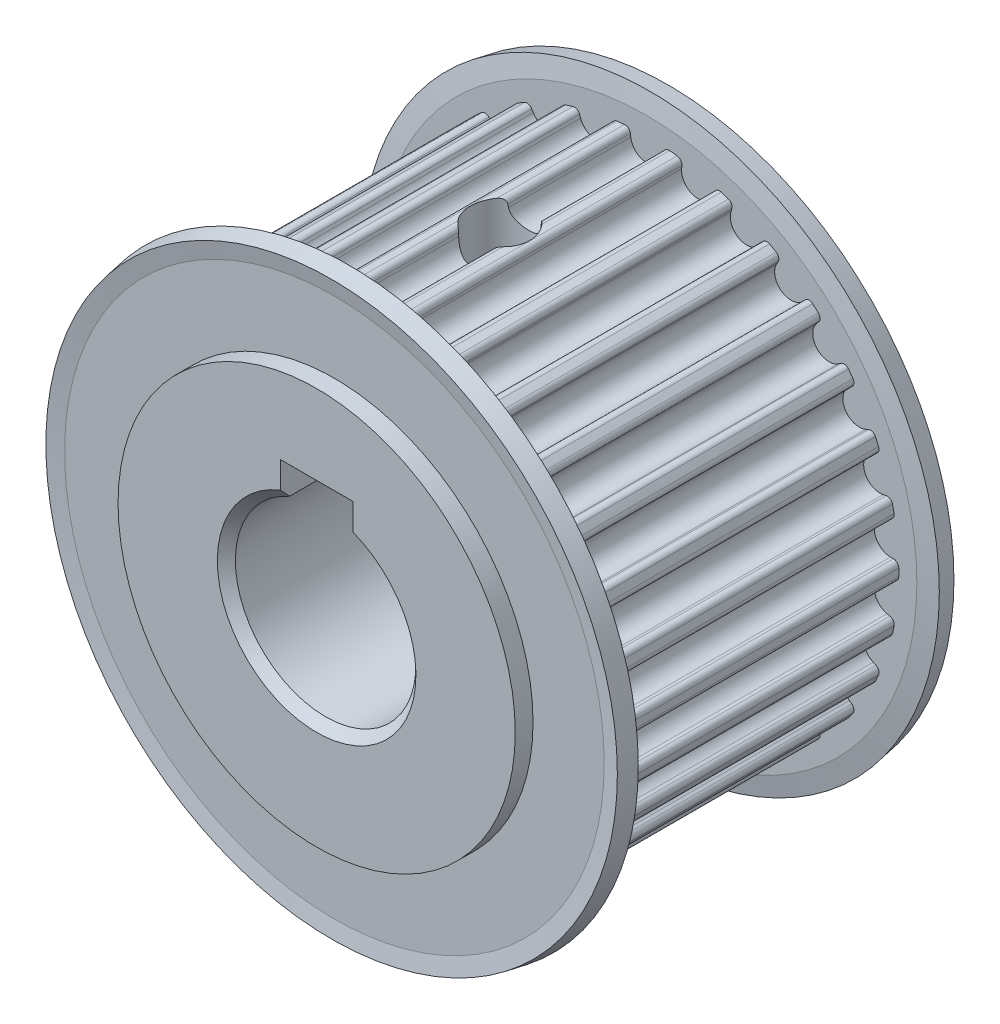
from build123d import *

# Parameters (mm, degrees)
TOOTH_EXTRUDE_START      = -8.15
TOOTH_EXTRUDE_DEPTH      = 16.3
TOOTH_PATTERN_COUNT      = 30
SKETCH_1_R               = 5
SKETCH_1_W               = 4
SKETCH_1_H               = 3.17973871
CUT_EXTRUDE_1_DEPTH      = 40
CHAMFER_1_SIZE           = 0.5
HOLE_WIZARD_M3_1_D       = 2.5
HOLE_WIZARD_M3_1_DEPTH   = 8.5
HOLE_WIZARD_M3_1_TIP     = 0.751075774
SKETCH_4_W               = 1.65
SKETCH_4_H               = 16
PATTERN_CIRCULAR_1_COUNT = 2
PATTERN_CIRCULAR_1_ANGLE = 90


with BuildPart() as part:
    # GearBelt-BaseSketch → HTD 5mm (revolve)
    with BuildSketch(Plane(origin=(0, 0, 0), x_dir=(0, 0, -1), z_dir=(1, 0, 0))):
        Polygon((-10.15, 0), (10.15, 0), (10.15, 11), (9.165426612, 11), (9.165426612, 14.942945123), (9.321195048, 15.826351822), (8.336387295, 16), (8.15, 14.942945123), (8.15, 13.942945123), (-8.15, 13.942945123), (-8.15, 14.942945123), (-8.336387295, 16), (-9.321195048, 15.826351822), (-9.165426612, 14.942945123), (-9.165426612, 11), (-10.15, 11), align=None)
    revolve(axis=Axis((0, 0, 10.8585), (0, 0, -1)))

    # Tooth-Sketch → Tooth-Extrude (cut)
    with BuildSketch(Plane.XY.offset(TOOTH_EXTRUDE_START)):
        with BuildLine():
            Line((-0.903216998, 13.46204402), (-0.923196237, 13.624761865))
            ThreePointArc((-0.923196237, 13.624761865), (-1.032437726, 13.821566271), (-1.247808246, 13.886997273))
            ThreePointArc((-1.247808246, 13.886997273), (0, 13.942945123), (1.247808246, 13.886997273))
            ThreePointArc((1.247808246, 13.886997273), (1.032437726, 13.821566271), (0.923196237, 13.624761865))
            Line((0.923196237, 13.624761865), (0.903216998, 13.46204402))
            ThreePointArc((0.903216998, 13.46204402), (0, 12.662945123), (-0.903216998, 13.46204402))
        make_face()
    tooth_extrude = extrude(amount=TOOTH_EXTRUDE_DEPTH, mode=Mode.SUBTRACT)

    # Tooth Pattern: Tooth-Extrude ×30 about axis
    tooth_pattern_axis = Axis((0, 0, 0), (0, 0, 1))
    for i in range(1, TOOTH_PATTERN_COUNT):
        add(tooth_extrude.rotate(tooth_pattern_axis, i * 360 / TOOTH_PATTERN_COUNT), mode=Mode.SUBTRACT)

    # Sketch 1 → Cut-Extrude 1 (cut)
    with BuildSketch(Plane.XY.offset(10.15)):
        Circle(SKETCH_1_R)
        with Locations((0, 5)):
            Rectangle(SKETCH_1_W, SKETCH_1_H)
    extrude(amount=-CUT_EXTRUDE_1_DEPTH, mode=Mode.SUBTRACT)

    # Chamfer 1
    chamfer_1_edges = [part.edges().sort_by_distance(p)[0] for p in [
        (0, -5, -10.15),
        (0, -5, 10.15),
    ]]
    chamfer(chamfer_1_edges, length=CHAMFER_1_SIZE)

    # Hole Wizard M3 _1
    with Locations(Plane(origin=(0, 0, -10.15), x_dir=(1, 0, 0), z_dir=(0, 0, -1))):
        with Locations((-10, 0), (10, 0)):
            Hole(HOLE_WIZARD_M3_1_D / 2, depth=HOLE_WIZARD_M3_1_DEPTH)
            with Locations((0, 0, -(HOLE_WIZARD_M3_1_DEPTH + HOLE_WIZARD_M3_1_TIP / 2))):  # 118° drill point
                Cone(0, HOLE_WIZARD_M3_1_D / 2, HOLE_WIZARD_M3_1_TIP, mode=Mode.SUBTRACT)

    # Sketch 4 → Hole Wizard M4 _1 (revolve, cut)
    with BuildSketch(Plane(origin=(0, 0, 0), x_dir=(0, 0, -1), z_dir=(1, 0, 0))):
        with Locations((0.825, 8)):
            Rectangle(SKETCH_4_W, SKETCH_4_H)
    hole_wizard_m4_1 = revolve(axis=Axis((0, -6.35, 0), (0, 1, 0)), mode=Mode.SUBTRACT)

    # Pattern Circular 1: Hole Wizard M4 _1 ×2 about axis
    pattern_circular_1_axis = Axis((0, 0, -29.85), (0, 0, 1))
    for i in range(1, PATTERN_CIRCULAR_1_COUNT):
        add(hole_wizard_m4_1.rotate(pattern_circular_1_axis, i * PATTERN_CIRCULAR_1_ANGLE / (PATTERN_CIRCULAR_1_COUNT - 1)), mode=Mode.SUBTRACT)


solid = part.part
